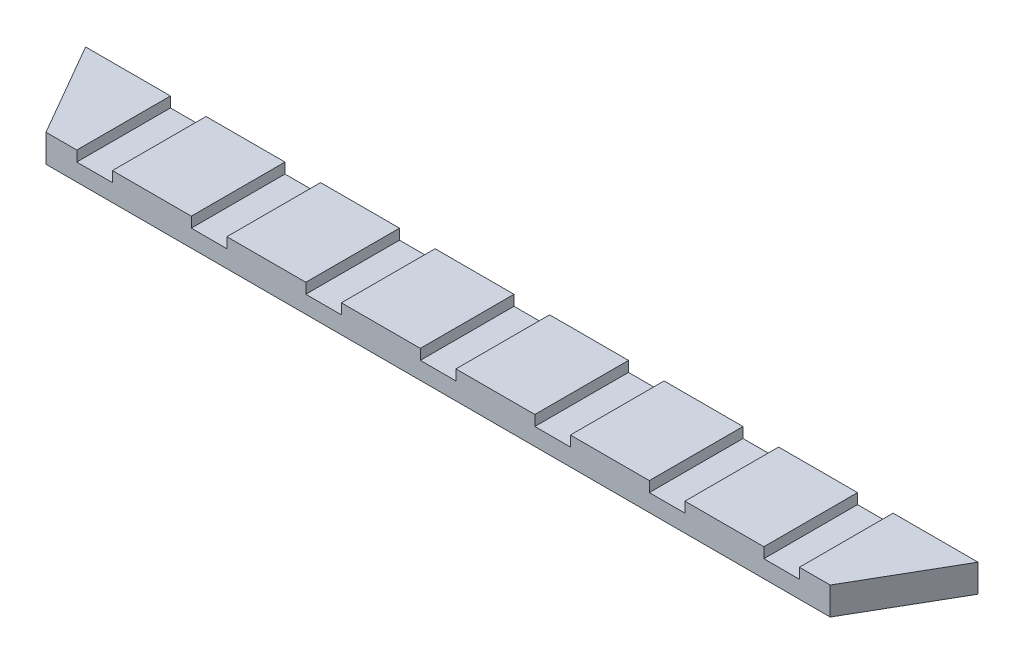
from build123d import *

# Parameters (mm, degrees)
BOSS_EXTRUDE1_DEPTH = 8
SKETCH4_W           = 10.258234738
SKETCH4_H           = 27
CUT_EXTRUDE1_DEPTH  = 3


with BuildPart() as part:
    # Sketch1 → Boss-Extrude1 (new body)
    with BuildSketch(Plane(origin=(0, 0, 0), x_dir=(1, 0, 0), z_dir=(0, 1, 0))):
        Polygon((-113, -12.62891462), (113, -12.62891462), (128.588457268, 14.37108538), (-128.588457268, 14.37108538), align=None)
    extrude(amount=BOSS_EXTRUDE1_DEPTH)

    # Sketch4 → Cut-Extrude1 (cut)
    with BuildSketch(Plane(origin=(0, 8, 0), x_dir=(1, 0, 0), z_dir=(0, 1, 0))):
        with Locations((-66, 0.87108538)):
            Rectangle(SKETCH4_W, SKETCH4_H)
        with Locations((-99, 0.87108538)):
            Rectangle(SKETCH4_W, SKETCH4_H)
        with Locations((-33, 0.87108538)):
            Rectangle(SKETCH4_W, SKETCH4_H)
        with Locations((0, 0.87108538)):
            Rectangle(SKETCH4_W, SKETCH4_H)
        with Locations((33, 0.87108538)):
            Rectangle(SKETCH4_W, SKETCH4_H)
        with Locations((66, 0.87108538)):
            Rectangle(SKETCH4_W, SKETCH4_H)
        with Locations((99, 0.87108538)):
            Rectangle(SKETCH4_W, SKETCH4_H)
    extrude(amount=-CUT_EXTRUDE1_DEPTH, mode=Mode.SUBTRACT)


solid = part.part
